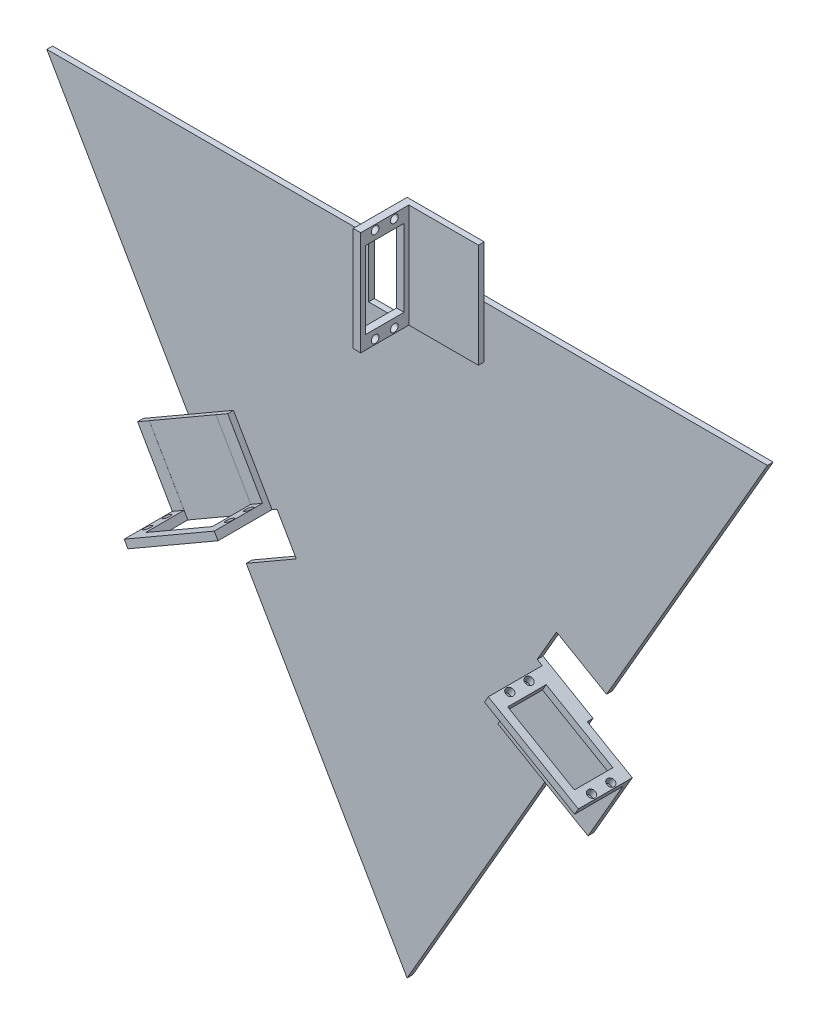
from build123d import *

# Parameters (mm, degrees)
BOSS_EXTRUDE1_DEPTH     = 3
SKETCH4_W               = 40
SKETCH4_H               = 54
BOSS_EXTRUDE2_DEPTH     = 3
SKETCH11_W              = 3.9
SKETCH11_H              = 54
BOSS_EXTRUDE3_DEPTH     = 25
SKETCH16_R              = 2
SKETCH16_W              = 20
SKETCH16_H              = 40
CUT_EXTRUDE2_DEPTH      = 184.1
CUT_EXTRUDE2_DEPTH_BACK = 191.9
SKETCH13_R              = 2
SKETCH13_W              = 40
SKETCH13_H              = 20
CUT_EXTRUDE3_DEPTH      = 211.382685902
CUT_EXTRUDE3_DEPTH_BACK = 281.5
SKETCH12_R              = 2
SKETCH12_W              = 40
SKETCH12_H              = 20
CUT_EXTRUDE4_DEPTH      = 281.5
CUT_EXTRUDE4_DEPTH_BACK = 211.382685902
SKETCH17_W              = 20
SKETCH17_H              = 30
CUT_EXTRUDE5_DEPTH      = 80


with BuildPart() as part:
    # Sketch2 → Boss-Extrude1 (new body)
    with BuildSketch(Plane.XY):
        Polygon((-187, 161.946750508), (187, 161.946750508), (0, -161.946750508), align=None)
    extrude(amount=BOSS_EXTRUDE1_DEPTH)

    # Sketch4 → Boss-Extrude2 (add)
    with BuildSketch(Plane.XY.offset(3)):
        Polygon((116.882685902, -13.5), (96.882685902, -48.141016151), (50.117314098, -21.141016151), (70.117314098, 13.5), align=None)
        Polygon((-116.882685902, -13.5), (-136.882685902, 21.141016151), (-90.117314098, 48.141016151), (-70.117314098, 13.5), align=None)
        with Locations((20, 161.946750508)):
            Rectangle(SKETCH4_W, SKETCH4_H)
    extrude(amount=BOSS_EXTRUDE2_DEPTH)

    # Sketch11 → Boss-Extrude3 (add)
    with BuildSketch(Plane.XY.offset(6)):
        Polygon((116.882685902, -13.5), (114.932685902, -16.877499075), (68.167314098, 10.122500925), (70.117314098, 13.5), align=None)
        Polygon((-116.882685902, -13.5), (-118.832685902, -10.122500925), (-72.067314098, 16.877499075), (-70.117314098, 13.5), align=None)
        with Locations((1.95, 161.946750508)):
            Rectangle(SKETCH11_W, SKETCH11_H)
    extrude(amount=BOSS_EXTRUDE3_DEPTH)

    # Sketch16 → Cut-Extrude2 (cut, two sides)
    with BuildSketch(Plane(origin=(3.9, 0, 0), x_dir=(0, 0, -1), z_dir=(1, 0, 0))) as cut_extrude2_sk:
        with Locations((-13.5, 186.446750508)):
            Circle(SKETCH16_R)
        with Locations((-23.5, 186.446750508)):
            Circle(SKETCH16_R)
        with Locations((-23.5, 137.446750508)):
            Circle(SKETCH16_R)
        with Locations((-13.5, 137.446750508)):
            Circle(SKETCH16_R)
        with Locations((-18.5, 161.946750508)):
            Rectangle(SKETCH16_W, SKETCH16_H)
    extrude(amount=CUT_EXTRUDE2_DEPTH, mode=Mode.SUBTRACT)
    extrude(cut_extrude2_sk.sketch, amount=-CUT_EXTRUDE2_DEPTH_BACK, mode=Mode.SUBTRACT)

    # Sketch13 → Cut-Extrude3 (cut, two sides)
    with BuildSketch(Plane(origin=(23.375, 40.486687627, 0), x_dir=(0.866025404, -0.5, 0), z_dir=(0.5, 0.866025404, 0))) as cut_extrude3_sk:
        with Locations((105.473375254, -22)):
            Circle(SKETCH13_R)
        with Locations((105.473375254, -12)):
            Circle(SKETCH13_R)
        with Locations((56.473375254, -12)):
            Circle(SKETCH13_R)
        with Locations((56.473375254, -22)):
            Circle(SKETCH13_R)
        with Locations((80.973375254, -17)):
            Rectangle(SKETCH13_W, SKETCH13_H)
    extrude(amount=CUT_EXTRUDE3_DEPTH, mode=Mode.SUBTRACT)
    extrude(cut_extrude3_sk.sketch, amount=-CUT_EXTRUDE3_DEPTH_BACK, mode=Mode.SUBTRACT)

    # Sketch12 → Cut-Extrude4 (cut, two sides)
    with BuildSketch(Plane(origin=(-23.375, 40.486687627, 0), x_dir=(0.866025404, 0.5, 0), z_dir=(0.5, -0.866025404, 0))) as cut_extrude4_sk:
        with Locations((-56.473375254, 10.981481481)):
            Circle(SKETCH12_R)
        with Locations((-56.473375254, 20.981481481)):
            Circle(SKETCH12_R)
        with Locations((-105.473375254, 20.981481481)):
            Circle(SKETCH12_R)
        with Locations((-105.473375254, 10.981481481)):
            Circle(SKETCH12_R)
        with Locations((-80.973375254, 15.981481481)):
            Rectangle(SKETCH12_W, SKETCH12_H)
    extrude(amount=CUT_EXTRUDE4_DEPTH, mode=Mode.SUBTRACT)
    extrude(cut_extrude4_sk.sketch, amount=-CUT_EXTRUDE4_DEPTH_BACK, mode=Mode.SUBTRACT)

    # Sketch17 → Cut-Extrude5 (cut, symmetric)
    with BuildSketch(Plane.XY.offset(3)):
        Polygon((-93.5, 0), (-67.519237886, 15), (-57.519237886, -2.320508076), (-83.5, -17.320508076), align=None)
        Polygon((93.5, 0), (103.5, 17.320508076), (77.519237886, 32.320508076), (67.519237886, 15), align=None)
        with Locations((-10, 146.946750508)):
            Rectangle(SKETCH17_W, SKETCH17_H)
    extrude(amount=CUT_EXTRUDE5_DEPTH, both=True, mode=Mode.SUBTRACT)


solid = part.part
